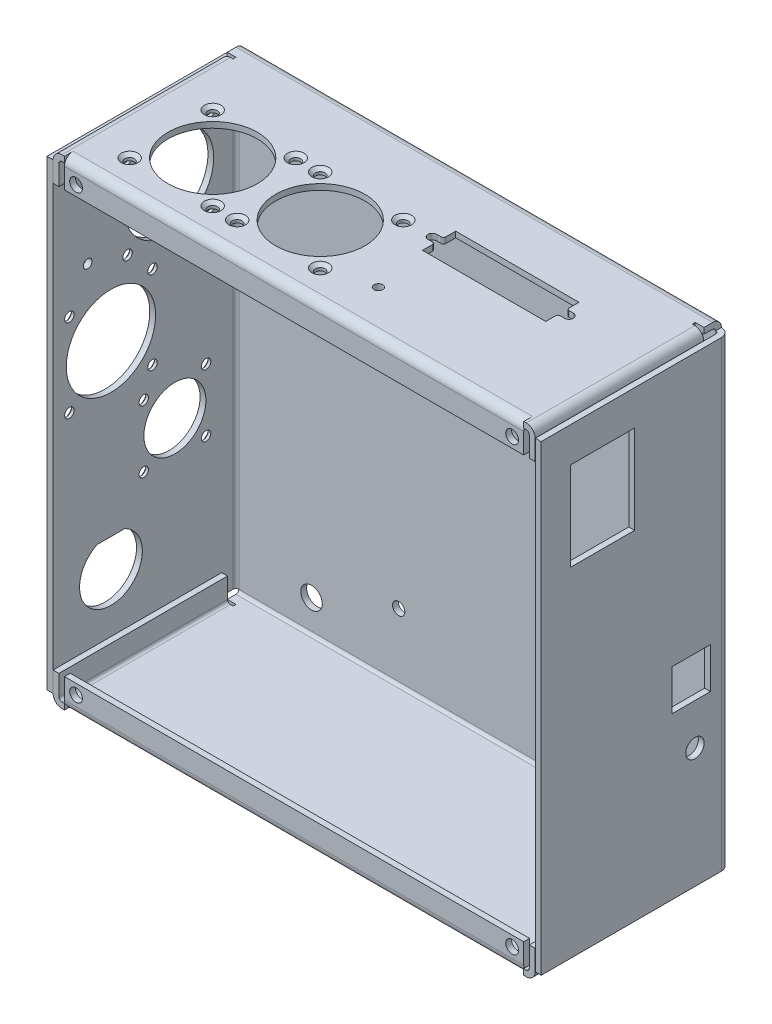
from build123d import *

# Parameters (mm, degrees)
SKETCH1_W                                         = 2
SKETCH1_H                                         = 159
EXTRUDE_THIN1_DEPTH                               = 82
BOSS_EXTRUDE3_DEPTH                               = 82
BOSS_EXTRUDE4_DEPTH                               = 79.5
CUT_EXTRUDE1_START                                = 4
SKETCH19_W                                        = 3.667088734
SKETCH19_H                                        = 24.82370558
CUT_EXTRUDE1_DEPTH                                = 131.165010342
BOSS_EXTRUDE5_START                               = 1
BOSS_EXTRUDE5_DEPTH                               = 58
MIRROR4_START                                     = 4
MIRROR4_COPY_1_SKETCH_W                           = 3.667088734
MIRROR4_COPY_1_SKETCH_H                           = 24.82370558
MIRROR4_COPY_1_DEPTH                              = 131.165010342
MIRROR4_START_2                                   = 1
MIRROR4_COPY_2_DEPTH                              = 58
SKETCH21_R                                        = 2.11
SKETCH21_R_2                                      = 3.695
CUT_EXTRUDE2_DEPTH                                = 135.165010342
SKETCH22_R                                        = 10.668
SKETCH22_R_2                                      = 1.25
SKETCH22_R_3                                      = 15.367
SKETCH22_R_4                                      = 1
SKETCH22_R_5                                      = 1.5
CUT_EXTRUDE3_DEPTH                                = 3
SKETCH23_R                                        = 15.367
SKETCH23_R_2                                      = 1
SKETCH23_R_3                                      = 1.5
CUT_EXTRUDE4_DEPTH                                = 3
CSK_FOR_4_FLAT_HEAD_MACHINE_SCREW_100_D           = 3.2639
CSK_FOR_4_FLAT_HEAD_MACHINE_SCREW_100_DEPTH       = 10
CSK_FOR_4_FLAT_HEAD_MACHINE_SCREW_100_CSINK_D     = 5.715
CSK_FOR_4_FLAT_HEAD_MACHINE_SCREW_100_CSINK_ANGLE = 100
CSK_FOR_4_FLAT_HEAD_MACHINE_SCREW_100_TIP         = 0.980574487
SKETCH26_R                                        = 2.195
CUT_EXTRUDE5_DEPTH                                = 10
SKETCH27_R                                        = 3.175
SKETCH27_W                                        = 22.15
SKETCH27_H                                        = 30.5
SKETCH27_W_2                                      = 13.303
SKETCH27_H_2                                      = 14
CUT_EXTRUDE6_DEPTH                                = 10
CSK_FOR_4_FLAT_HEAD_MACHINE_SCREW_2_D             = 3.2639
CSK_FOR_4_FLAT_HEAD_MACHINE_SCREW_2_DEPTH         = 10
CSK_FOR_4_FLAT_HEAD_MACHINE_SCREW_2_CSINK_D       = 5.715
CSK_FOR_4_FLAT_HEAD_MACHINE_SCREW_2_CSINK_ANGLE   = 100
CSK_FOR_4_FLAT_HEAD_MACHINE_SCREW_2_TIP           = 0.980574487


with BuildPart() as part:
    # Sketch1 → Extrude-Thin1 (new, symmetric)
    with BuildSketch(Plane(origin=(0, 0, 0), x_dir=(0, 0, -1), z_dir=(1, 0, 0))):
        with Locations((-1, 0)):
            Rectangle(SKETCH1_W, SKETCH1_H)
    extrude(amount=EXTRUDE_THIN1_DEPTH, both=True)

    # Sketch16 → Boss-Extrude3 (add, symmetric)
    with BuildSketch(Plane(origin=(0, 0, 0), x_dir=(0, 0, -1), z_dir=(1, 0, 0))):
        with BuildLine():
            Line((-3, 80.5), (-62, 80.5))
            ThreePointArc((-62, 80.5), (-62.707106781, 80.207106781), (-63, 79.5))
            Line((-63, 79.5), (-63, 72.5))
            Line((-63, 72.5), (-65, 72.5))
            Line((-65, 72.5), (-65, 79.5))
            ThreePointArc((-65, 79.5), (-64.121320344, 81.621320344), (-62, 82.5))
            Line((-62, 82.5), (-3, 82.5))
            ThreePointArc((-3, 82.5), (-0.878679656, 81.621320344), (0, 79.5))
            Line((0, 79.5), (-2, 79.5))
            ThreePointArc((-2, 79.5), (-2.292893219, 80.207106781), (-3, 80.5))
        make_face()
    boss_extrude3 = extrude(amount=BOSS_EXTRUDE3_DEPTH, both=True)

    # Mirror1: Boss-Extrude3 across plane
    add(boss_extrude3.mirror(Plane.ZX))

    # Sketch18 → Boss-Extrude4 (add, symmetric)
    with BuildSketch(Plane(origin=(0, 0, 0), x_dir=(1, 0, 0), z_dir=(0, 1, 0))):
        with BuildLine():
            Line((-85, -3), (-85, -65))
            Line((-85, -65), (-83, -65))
            Line((-83, -65), (-83, -3))
            ThreePointArc((-83, -3), (-82.707106781, -2.292893219), (-82, -2))
            Line((-82, -2), (-82, 0))
            ThreePointArc((-82, 0), (-84.121320344, -0.878679656), (-85, -3))
        make_face()
    boss_extrude4 = extrude(amount=BOSS_EXTRUDE4_DEPTH, both=True)

    # Mirror2: Boss-Extrude4 across plane
    add(boss_extrude4.mirror(Plane(origin=(0, 0, 0), x_dir=(0, 0, 1), z_dir=(1, 0, 0))))

    # Sketch19 → Cut-Extrude1 (cut, through all)
    with BuildSketch(Plane.XY.offset(2).offset(CUT_EXTRUDE1_START)):
        with Locations((-80.833544367, 76.879365048)):
            Rectangle(SKETCH19_W, SKETCH19_H)
    cut_extrude1 = extrude(amount=CUT_EXTRUDE1_DEPTH, mode=Mode.SUBTRACT)

    # Sketch20 → Boss-Extrude5 (add)
    with BuildSketch(Plane.XY.offset(6).offset(BOSS_EXTRUDE5_START)):
        with BuildLine():
            Line((-79, 80.5), (-79, 82.5))
            Line((-79, 82.5), (-79.9, 82.5))
            ThreePointArc((-79.9, 82.5), (-82.021320344, 81.621320344), (-82.9, 79.5))
            Line((-82.9, 79.5), (-82.9, 72.5))
            Line((-82.9, 72.5), (-80.9, 72.5))
            Line((-80.9, 72.5), (-80.9, 79.5))
            ThreePointArc((-80.9, 79.5), (-80.607106781, 80.207106781), (-79.9, 80.5))
            Line((-79.9, 80.5), (-79, 80.5))
        make_face()
    boss_extrude5 = extrude(amount=BOSS_EXTRUDE5_DEPTH)

    # Mirror3: Cut-Extrude1, Boss-Extrude5 across plane
    add(cut_extrude1.mirror(Plane(origin=(0, 0, 0), x_dir=(0, 0, 1), z_dir=(1, 0, 0))), mode=Mode.SUBTRACT)
    add(boss_extrude5.mirror(Plane(origin=(0, 0, 0), x_dir=(0, 0, 1), z_dir=(1, 0, 0))))

    # Mirror4: Cut-Extrude1, Boss-Extrude5 across plane
    add(cut_extrude1.mirror(Plane.ZX), mode=Mode.SUBTRACT)
    add(boss_extrude5.mirror(Plane.ZX))

    # Mirror4 copy 1 sketch → Mirror4 copy 1 (cut, through all)
    with BuildSketch(Plane(origin=(0, 0, 2), x_dir=(-1, 0, 0), z_dir=(0, 0, 1)).offset(MIRROR4_START)):
        with Locations((-80.833544367, 76.879365048)):
            Rectangle(MIRROR4_COPY_1_SKETCH_W, MIRROR4_COPY_1_SKETCH_H)
    extrude(amount=MIRROR4_COPY_1_DEPTH, mode=Mode.SUBTRACT)

    # Mirror4 copy 2 sketch → Mirror4 copy 2 (add)
    with BuildSketch(Plane(origin=(0, 0, 6), x_dir=(-1, 0, 0), z_dir=(0, 0, 1)).offset(MIRROR4_START_2)):
        with BuildLine():
            Line((-79, 80.5), (-79, 82.5))
            Line((-79, 82.5), (-79.9, 82.5))
            ThreePointArc((-79.9, 82.5), (-82.021320344, 81.621320344), (-82.9, 79.5))
            Line((-82.9, 79.5), (-82.9, 72.5))
            Line((-82.9, 72.5), (-80.9, 72.5))
            Line((-80.9, 72.5), (-80.9, 79.5))
            ThreePointArc((-80.9, 79.5), (-80.607106781, 80.207106781), (-79.9, 80.5))
            Line((-79.9, 80.5), (-79, 80.5))
        make_face()
    extrude(amount=MIRROR4_COPY_2_DEPTH)

    # Sketch21 → Cut-Extrude2 (cut, through all)
    with BuildSketch(Plane.XY.offset(2)):
        with Locations((-27.02, 37.5)):
            Circle(SKETCH21_R)
        with Locations((-27.02, -57.75)):
            Circle(SKETCH21_R)
        with Locations((69.5, 37.5)):
            Circle(SKETCH21_R)
        with Locations((69.5, -57.75)):
            Circle(SKETCH21_R)
        with Locations((-57, 69.5)):
            Circle(SKETCH21_R_2)
        with Locations((-57, -69.5)):
            Circle(SKETCH21_R_2)
        with Locations((57, -69.5)):
            Circle(SKETCH21_R_2)
        with Locations((57, 69.5)):
            Circle(SKETCH21_R_2)
    extrude(amount=-CUT_EXTRUDE2_DEPTH, mode=Mode.SUBTRACT)

    # Sketch22 → Cut-Extrude3 (cut)
    with BuildSketch(Plane.ZY.offset(85)):
        with Locations((23, -18.5)):
            Circle(SKETCH22_R)
        with Locations((12.28, -7.78)):
            Circle(SKETCH22_R_2)
        with Locations((33.72, -7.78)):
            Circle(SKETCH22_R_2)
        with Locations((33.72, -29.22)):
            Circle(SKETCH22_R_2)
        with Locations((12.28, -29.22)):
            Circle(SKETCH22_R_2)
        with Locations((25, 52.5)):
            Circle(SKETCH22_R_3)
        with Locations((45, 15.5)):
            Circle(SKETCH22_R_3)
        with Locations((10.7125, 66.7875)):
            Circle(SKETCH22_R_4)
        with Locations((10.7125, 38.2125)):
            Circle(SKETCH22_R_4)
        with Locations((30.7125, 29.7875)):
            Circle(SKETCH22_R_4)
        with Locations((30.7125, 1.2125)):
            Circle(SKETCH22_R_4)
        with Locations((59.2875, 1.2125)):
            Circle(SKETCH22_R_4)
        with Locations((59.2875, 29.7875)):
            Circle(SKETCH22_R_4)
        with Locations((39.2875, 38.2125)):
            Circle(SKETCH22_R_4)
        with Locations((39.2875, 66.7875)):
            Circle(SKETCH22_R_4)
        with Locations((53, 42.5)):
            Circle(SKETCH22_R_5)
        with BuildLine():
            Line((40.251315972, -42.8), (49.748684028, -42.8))
            ThreePointArc((49.748684028, -42.8), (45, -63.3), (40.251315972, -42.8))
        make_face()
    extrude(amount=-CUT_EXTRUDE3_DEPTH, mode=Mode.SUBTRACT)

    # Sketch23 → Cut-Extrude4 (cut)
    with BuildSketch(Plane(origin=(0, 82.5, 0), x_dir=(1, 0, 0), z_dir=(0, 1, 0))):
        with Locations(Location((-53, -40, 0), (0, 0, 270))):
            Circle(SKETCH23_R)
        with Locations(Location((-16, -40, 0), (0, 0, 270))):
            Circle(SKETCH23_R)
        with Locations(Location((-30.2875, -25.7125, 0), (0, 0, 270))):
            Circle(SKETCH23_R_2)
        with Locations(Location((-1.7125, -25.7125, 0), (0, 0, 270))):
            Circle(SKETCH23_R_2)
        with Locations(Location((-1.7125, -54.2875, 0), (0, 0, 270))):
            Circle(SKETCH23_R_2)
        with Locations(Location((-30.2875, -54.2875, 0), (0, 0, 270))):
            Circle(SKETCH23_R_2)
        with Locations(Location((-38.7125, -54.2875, 0), (0, 0, 270))):
            Circle(SKETCH23_R_2)
        with Locations(Location((-38.7125, -25.7125, 0), (0, 0, 270))):
            Circle(SKETCH23_R_2)
        with Locations(Location((-67.2875, -25.7125, 0), (0, 0, 270))):
            Circle(SKETCH23_R_2)
        with Locations(Location((-67.2875, -54.2875, 0), (0, 0, 270))):
            Circle(SKETCH23_R_2)
        with Locations(Location((14, -50, 0), (0, 0, 270))):
            Circle(SKETCH23_R_3)
        with BuildLine():
            Line((10.6, -20), (53, -20))
            Line((53, -20), (53, -23.3782))
            ThreePointArc((53, -23.3782), (53.238063608, -23.952936392), (53.8128, -24.191))
            Line((53.8128, -24.191), (55.3, -24.191))
            ThreePointArc((55.3, -24.191), (56.824, -25.715), (55.3, -27.239))
            Line((55.3, -27.239), (53.8128, -27.239))
            ThreePointArc((53.8128, -27.239), (53.238063608, -27.477063608), (53, -28.0518))
            Line((53, -28.0518), (53, -31.43))
            Line((53, -31.43), (10.6, -31.43))
            Line((10.6, -31.43), (10.6, -28.0518))
            ThreePointArc((10.6, -28.0518), (10.361936392, -27.477063608), (9.7872, -27.239))
            Line((9.7872, -27.239), (8.3, -27.239))
            ThreePointArc((8.3, -27.239), (6.776, -25.715), (8.3, -24.191))
            Line((8.3, -24.191), (9.7872, -24.191))
            ThreePointArc((9.7872, -24.191), (10.361936392, -23.952936392), (10.6, -23.3782))
            Line((10.6, -23.3782), (10.6, -20))
        make_face()
    extrude(amount=-CUT_EXTRUDE4_DEPTH, mode=Mode.SUBTRACT)

    # CSK for _4 Flat Head Machine Screw _100
    with Locations(Plane.ZY.offset(85)):
        with Locations((12.28, -7.78), (33.72, -7.78), (33.72, -29.22), (12.28, -29.22), (10.7125, 66.7875), (39.2875, 66.7875), (39.2875, 38.2125), (59.2875, 29.7875), (59.2875, 1.2125), (30.7125, 1.2125), (30.7125, 29.7875), (10.7125, 38.2125)):
            CounterSinkHole(CSK_FOR_4_FLAT_HEAD_MACHINE_SCREW_100_D / 2, CSK_FOR_4_FLAT_HEAD_MACHINE_SCREW_100_CSINK_D / 2, depth=CSK_FOR_4_FLAT_HEAD_MACHINE_SCREW_100_DEPTH, counter_sink_angle=CSK_FOR_4_FLAT_HEAD_MACHINE_SCREW_100_CSINK_ANGLE)
            with Locations((0, 0, -(CSK_FOR_4_FLAT_HEAD_MACHINE_SCREW_100_DEPTH + CSK_FOR_4_FLAT_HEAD_MACHINE_SCREW_100_TIP / 2))):  # 118° drill point
                Cone(0, CSK_FOR_4_FLAT_HEAD_MACHINE_SCREW_100_D / 2, CSK_FOR_4_FLAT_HEAD_MACHINE_SCREW_100_TIP, mode=Mode.SUBTRACT)

    # Sketch26 → Cut-Extrude5 (cut)
    with BuildSketch(Plane.XY.offset(65)):
        with Locations((-75, 76)):
            Circle(SKETCH26_R)
        with Locations((75, 76)):
            Circle(SKETCH26_R)
        with Locations((75, -76)):
            Circle(SKETCH26_R)
        with Locations((-75, -76)):
            Circle(SKETCH26_R)
    extrude(amount=-CUT_EXTRUDE5_DEPTH, mode=Mode.SUBTRACT)

    # Sketch27 → Cut-Extrude6 (cut)
    with BuildSketch(Plane(origin=(85, 0, 0), x_dir=(0, 0, -1), z_dir=(1, 0, 0))):
        with Locations((-12.096, -38.26)):
            Circle(SKETCH27_R)
        with Locations((-43.925, 52.25)):
            Rectangle(SKETCH27_W, SKETCH27_H)
        with Locations((-13.4295, -17.08)):
            Rectangle(SKETCH27_W_2, SKETCH27_H_2)
    extrude(amount=-CUT_EXTRUDE6_DEPTH, mode=Mode.SUBTRACT)

    # CSK for _4 Flat Head Machine Screw _ 2
    with Locations(Plane(origin=(0, 82.5, 0), x_dir=(-1, 0, 0), z_dir=(0, 1, 0))):
        with Locations((67.2875, 25.7125), (38.7125, 25.7125), (30.2875, 25.7125), (1.7125, 25.7125), (1.7125, 54.2875), (30.2875, 54.2875), (38.7125, 54.2875), (67.2875, 54.2875)):
            CounterSinkHole(CSK_FOR_4_FLAT_HEAD_MACHINE_SCREW_2_D / 2, CSK_FOR_4_FLAT_HEAD_MACHINE_SCREW_2_CSINK_D / 2, depth=CSK_FOR_4_FLAT_HEAD_MACHINE_SCREW_2_DEPTH, counter_sink_angle=CSK_FOR_4_FLAT_HEAD_MACHINE_SCREW_2_CSINK_ANGLE)
            with Locations((0, 0, -(CSK_FOR_4_FLAT_HEAD_MACHINE_SCREW_2_DEPTH + CSK_FOR_4_FLAT_HEAD_MACHINE_SCREW_2_TIP / 2))):  # 118° drill point
                Cone(0, CSK_FOR_4_FLAT_HEAD_MACHINE_SCREW_2_D / 2, CSK_FOR_4_FLAT_HEAD_MACHINE_SCREW_2_TIP, mode=Mode.SUBTRACT)


solid = part.part
